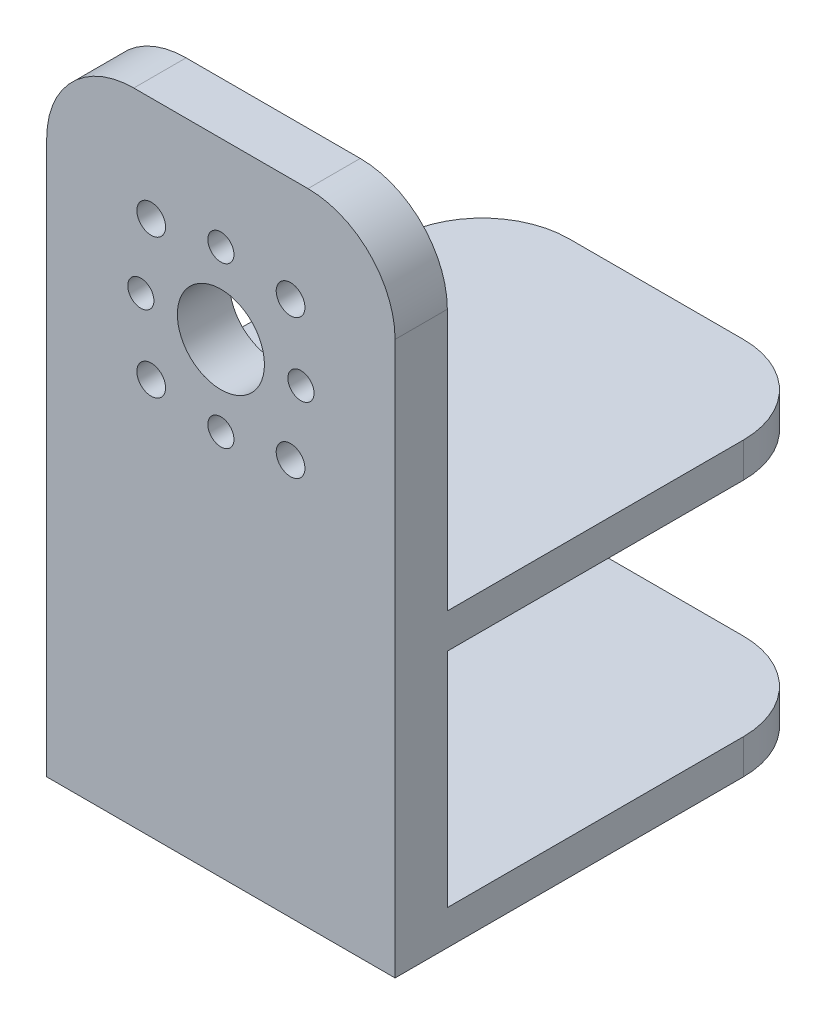
from build123d import *

# Parameters (mm, degrees)
SKETCH1_W           = 40
SKETCH1_H           = 40
SKETCH1_R           = 5
SKETCH1_R_2         = 1.65
SKETCH1_R_3         = 1.5
BOSS_EXTRUDE1_DEPTH = 6
SKETCH2_W           = 6
SKETCH2_H           = 25.5
BOSS_EXTRUDE2_DEPTH = 40
SKETCH3_R           = 3.5
CUT_EXTRUDE1_DEPTH  = 3
FILLET1_R           = 10


with BuildPart() as part:
    # Sketch1 → Boss-Extrude1 (new body)
    with BuildSketch(Plane.XY):
        with Locations((20, 20)):
            Rectangle(SKETCH1_W, SKETCH1_H)
        with Locations((20, 20)):
            Circle(SKETCH1_R, mode=Mode.SUBTRACT)
        with Locations((12, 28)):
            Circle(SKETCH1_R_2, mode=Mode.SUBTRACT)
        with Locations((20, 29.192388155)):
            Circle(SKETCH1_R_3, mode=Mode.SUBTRACT)
        with Locations((29.192388155, 20)):
            Circle(SKETCH1_R_3, mode=Mode.SUBTRACT)
        with Locations((20, 10.807611845)):
            Circle(SKETCH1_R_3, mode=Mode.SUBTRACT)
        with Locations((10.807611845, 20)):
            Circle(SKETCH1_R_3, mode=Mode.SUBTRACT)
        with Locations((28, 28)):
            Circle(SKETCH1_R_2, mode=Mode.SUBTRACT)
        with Locations((12, 12)):
            Circle(SKETCH1_R_2, mode=Mode.SUBTRACT)
        with Locations((28, 12)):
            Circle(SKETCH1_R_2, mode=Mode.SUBTRACT)
    extrude(amount=BOSS_EXTRUDE1_DEPTH)

    # Sketch2 → Boss-Extrude2 (add)
    with BuildSketch(Plane(origin=(40, 0, 0), x_dir=(0, 0, -1), z_dir=(1, 0, 0))):
        Polygon((44, 0), (-6, 0), (-6, -4), (0, -4), (44, -4), align=None)
        with Locations((-3, -16.75)):
            Rectangle(SKETCH2_W, SKETCH2_H)
        Polygon((0, -29.5), (-6, -29.5), (-6, -33.5), (44, -33.5), (44, -29.5), align=None)
    extrude(amount=-BOSS_EXTRUDE2_DEPTH)

    # Sketch3 → Cut-Extrude1 (cut)
    with BuildSketch(Plane(origin=(0, 0, 0), x_dir=(-1, 0, 0), z_dir=(0, 0, -1))):
        with Locations((-20, 29.192388155)):
            Circle(SKETCH3_R)
        with Locations((-20, 10.807611845)):
            Circle(SKETCH3_R)
        with Locations((-29.192388155, 20)):
            Circle(SKETCH3_R)
        with Locations((-10.807611845, 20)):
            Circle(SKETCH3_R)
    extrude(amount=-CUT_EXTRUDE1_DEPTH, mode=Mode.SUBTRACT)

    # Fillet1
    fillet1_edges = [part.edges().sort_by_distance(p)[0] for p in [
        (40, -2, -44),
        (0, -31.5, -44),
        (0, -2, -44),
        (40, -31.5, -44),
        (0, 40, 3),
        (40, 40, 3),
    ]]
    fillet(fillet1_edges, radius=FILLET1_R)


solid = part.part
